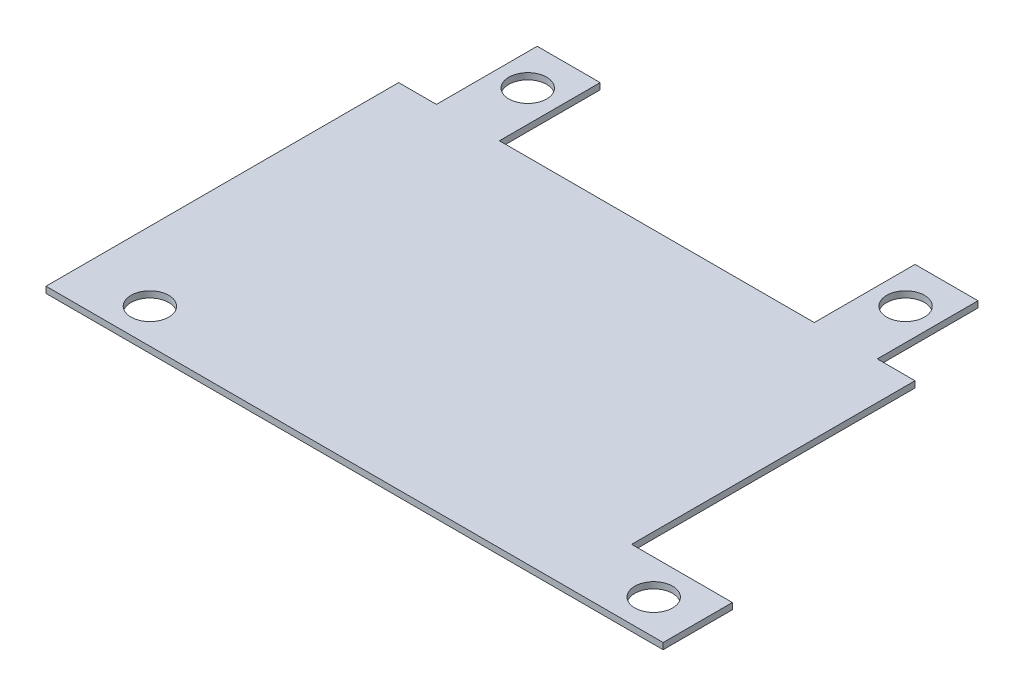
from build123d import *

# Parameters (mm, degrees)
SKETCH1_W           = 41
SKETCH1_H           = 28
BOSS_EXTRUDE1_DEPTH = 0.5
SKETCH2_R           = 1.5
SKETCH2_W           = 5
SKETCH2_H           = 8
SKETCH2_W_2         = 8
SKETCH2_H_2         = 5.5
BOSS_EXTRUDE2_DEPTH = 0.5
SKETCH3_R           = 1.5
CUT_EXTRUDE1_DEPTH  = 1.5


with BuildPart() as part:
    # Sketch1 → Boss-Extrude1 (new body)
    with BuildSketch(Plane(origin=(0, 0, 0), x_dir=(1, 0, 0), z_dir=(0, 1, 0))):
        Rectangle(SKETCH1_W, SKETCH1_H)
    extrude(amount=BOSS_EXTRUDE1_DEPTH)

    # Sketch2 → Boss-Extrude2 (add)
    with BuildSketch(Plane(origin=(0, 0, 0), x_dir=(1, 0, 0), z_dir=(0, 1, 0))):
        with Locations((-15, -11.25)):
            Circle(SKETCH2_R)
        with Locations((-15, 18)):
            Rectangle(SKETCH2_W, SKETCH2_H)
        with Locations((-15, 18.75)):
            Circle(SKETCH2_R, mode=Mode.SUBTRACT)
        with Locations((15, 18)):
            Rectangle(SKETCH2_W, SKETCH2_H)
        with Locations((15, 18.75)):
            Circle(SKETCH2_R, mode=Mode.SUBTRACT)
        with Locations((24.5, -11.25)):
            Rectangle(SKETCH2_W_2, SKETCH2_H_2)
        with Locations((25, -11.25)):
            Circle(SKETCH2_R, mode=Mode.SUBTRACT)
    extrude(amount=BOSS_EXTRUDE2_DEPTH)

    # Sketch3 → Cut-Extrude1 (cut, through all)
    with BuildSketch(Plane(origin=(0, 0.5, 0), x_dir=(1, 0, 0), z_dir=(0, 1, 0))):
        with Locations((-15, -11.25)):
            Circle(SKETCH3_R)
    extrude(amount=-CUT_EXTRUDE1_DEPTH, mode=Mode.SUBTRACT)


solid = part.part
